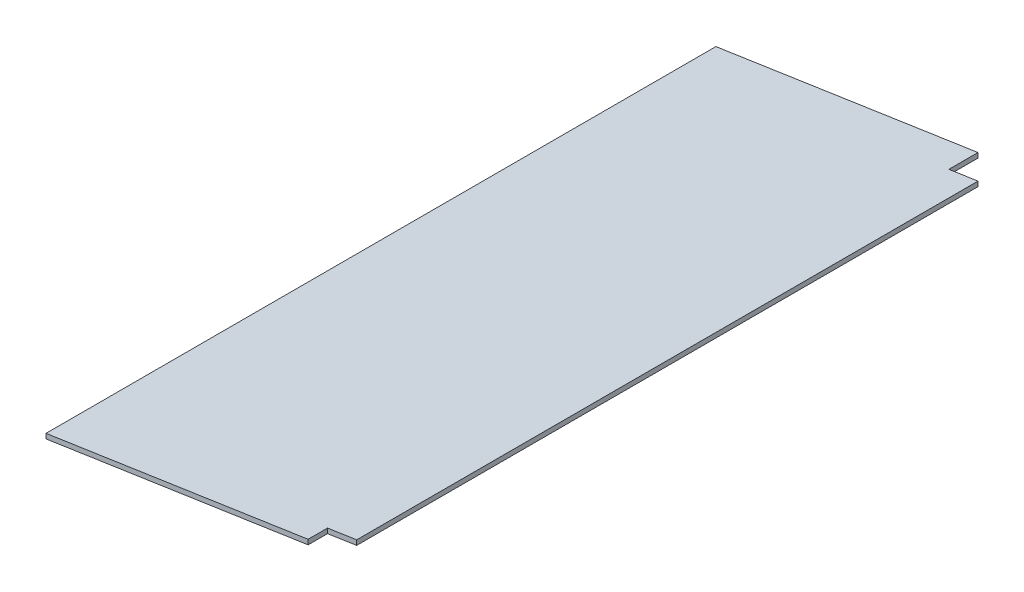
from build123d import *

# Parameters (mm, degrees)
BOSS_EXTRUDE1_DEPTH = 690
SKETCH3_W           = 30
SKETCH3_H           = 20
SKETCH3_H_2         = 30
CUT_EXTRUDE2_DEPTH  = 51


with BuildPart() as part:
    # Sketch1 → Boss-Extrude1 (new body)
    with BuildSketch(Plane.XY):
        Polygon((0, 5), (0, 0), (300, 45), (300, 50), align=None)
    extrude(amount=BOSS_EXTRUDE1_DEPTH)

    # Sketch3 → Cut-Extrude2 (cut, through all)
    with BuildSketch(Plane(origin=(0, 0, 0), x_dir=(1, 0, 0), z_dir=(0, 1, 0))):
        with Locations((285, -680)):
            Rectangle(SKETCH3_W, SKETCH3_H)
        with Locations((285, -15)):
            Rectangle(SKETCH3_W, SKETCH3_H_2)
    extrude(amount=CUT_EXTRUDE2_DEPTH, mode=Mode.SUBTRACT)


solid = part.part
